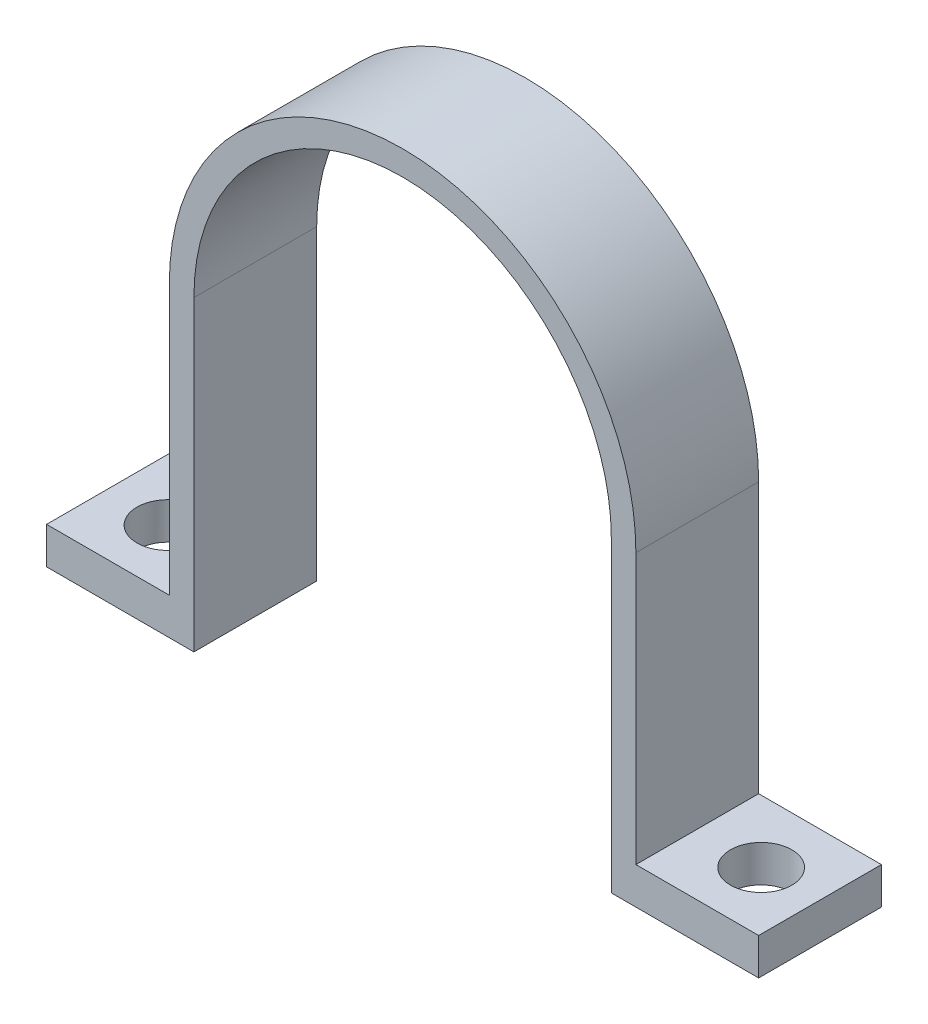
from build123d import *

# Parameters (mm, degrees)
BOSS_EXTRUDE1_DEPTH = 10
SKETCH2_R           = 2.534927605
SKETCH2_R_2         = 2.5
CUT_EXTRUDE1_DEPTH  = 10


with BuildPart() as part:
    # Sketch1 → Boss-Extrude1 (new body)
    with BuildSketch(Plane.XY):
        with BuildLine():
            Line((-17, 0), (-17, -24))
            Line((-17, -24), (-17, -25))
            Line((-17, -25), (-29, -25))
            Line((-29, -25), (-29, -22))
            Line((-29, -22), (-19, -22))
            Line((-19, -22), (-19, 0))
            ThreePointArc((-19, 0), (0, 19), (19, 0))
            Line((19, 0), (19, -22))
            Line((19, -22), (29, -22))
            Line((29, -22), (29, -25))
            Line((29, -25), (17, -25))
            Line((17, -25), (17, -24))
            Line((17, -24), (17, 0))
            ThreePointArc((17, 0), (0, 17), (-17, 0))
        make_face()
    extrude(amount=BOSS_EXTRUDE1_DEPTH)

    # Sketch2 → Cut-Extrude1 (cut)
    with BuildSketch(Plane(origin=(0, -22, 0), x_dir=(1, 0, 0), z_dir=(0, 1, 0))):
        with Locations((-24, -5.101003531)):
            Circle(SKETCH2_R)
        with Locations((24.304859837, -5.101003531)):
            Circle(SKETCH2_R_2)
    extrude(amount=-CUT_EXTRUDE1_DEPTH, mode=Mode.SUBTRACT)


solid = part.part
